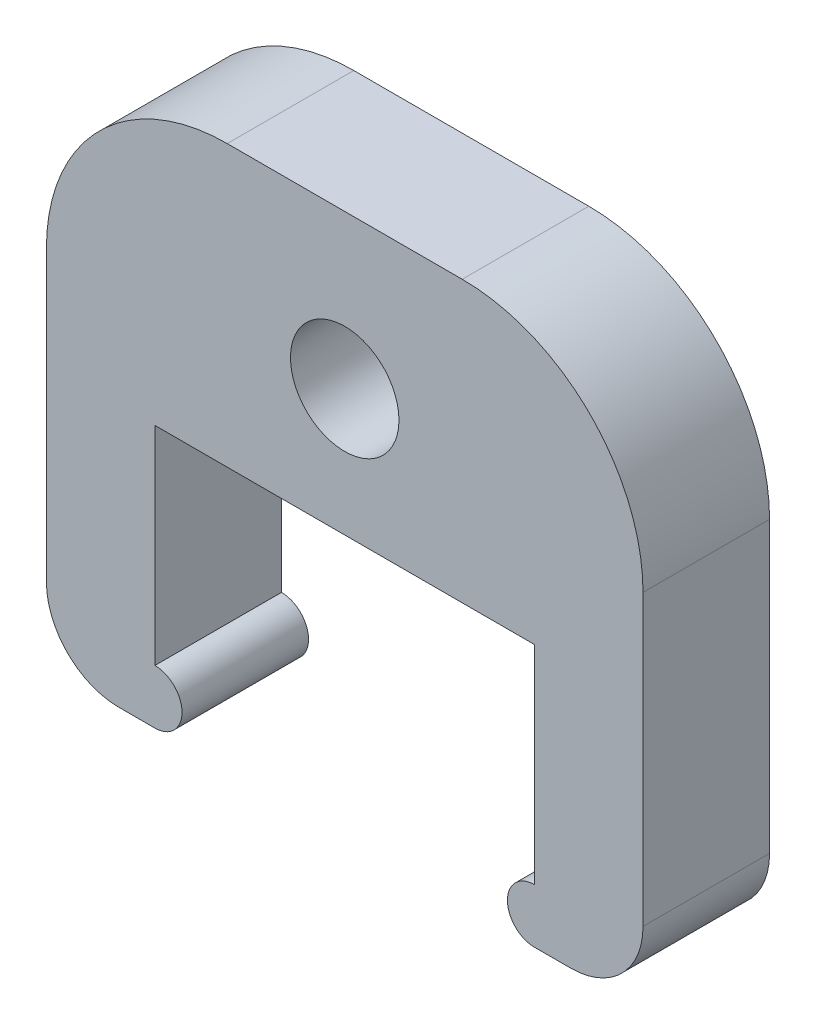
from build123d import *

# Parameters (mm, degrees)
SKETCH1_R           = 1.5
BOSS_EXTRUDE1_DEPTH = 3.5
FILLET1_R           = 2
FILLET2_R           = 5


with BuildPart() as part:
    # Sketch1 → Boss-Extrude1 (new body)
    with BuildSketch(Plane.XY):
        with BuildLine():
            Line((0, 15), (16.5, 15))
            Line((16.5, 15), (16.5, 0))
            Line((16.5, 0), (13.5, 0))
            ThreePointArc((13.5, 0), (12.75, 0.75), (13.5, 1.5))
            Line((13.5, 1.5), (13.5, 7.25))
            Line((13.5, 7.25), (3, 7.25))
            Line((3, 7.25), (3, 1.5))
            ThreePointArc((3, 1.5), (3.75, 0.75), (3, 0))
            Line((3, 0), (0, 0))
            Line((0, 0), (0, 15))
        make_face()
        with Locations((8.25, 10.75)):
            Circle(SKETCH1_R, mode=Mode.SUBTRACT)
    extrude(amount=BOSS_EXTRUDE1_DEPTH)

    # Fillet1
    fillet1_edges = [part.edges().sort_by_distance(p)[0] for p in [
        (16.5, 0, 1.75),
        (0, 0, 1.75),
    ]]
    fillet(fillet1_edges, radius=FILLET1_R)

    # Fillet2
    fillet2_edges = [part.edges().sort_by_distance(p)[0] for p in [
        (0, 15, 1.75),
        (16.5, 15, 1.75),
    ]]
    fillet(fillet2_edges, radius=FILLET2_R)


solid = part.part
